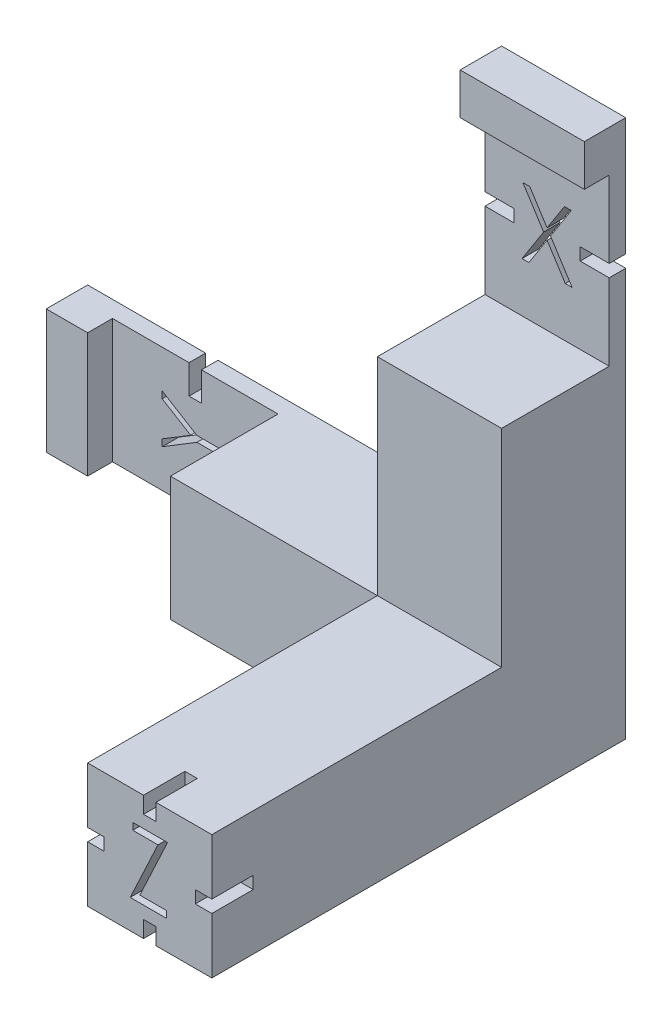
from build123d import *

# Parameters (mm, degrees)
CROQUIS2_W                = 25
CROQUIS2_H                = 15
SALIENTE_EXTRUIR1_DEPTH   = 15
CROQUIS2_W_2              = 15
CROQUIS2_H_2              = 25
SALIENTE_EXTRUIR1_2_DEPTH = 15
CROQUIS2_3_W              = 15
CROQUIS2_3_H              = 15
SALIENTE_EXTRUIR2_DEPTH   = 50
CROQUIS3_W                = 15
CROQUIS3_H                = 20
CROQUIS3_W_2              = 20
CROQUIS3_H_2              = 15
SALIENTE_EXTRUIR3_DEPTH   = 2
CROQUIS3_3_W              = 15
CROQUIS3_3_H              = 5
CROQUIS3_3_W_2            = 5
CROQUIS3_3_H_2            = 15
SALIENTE_EXTRUIR4_DEPTH   = 5
CROQUIS4_W                = 3.5
CROQUIS4_H                = 1.5
CROQUIS4_W_2              = 1.5
CROQUIS4_H_2              = 3.5
CORTAR_EXTRUIR1_DEPTH     = 15
CROQUIS5_W                = 1.5
CROQUIS5_H                = 2
CROQUIS5_W_2              = 2
CROQUIS5_H_2              = 1.5
CORTAR_EXTRUIR2_DEPTH     = 5


with BuildPart() as part:
    # Croquis2 → Saliente-Extruir1 (new body)
    with BuildSketch(Plane.XY):
        with Locations((-27.5, 7.5)):
            Rectangle(CROQUIS2_W, CROQUIS2_H)
    extrude(amount=SALIENTE_EXTRUIR1_DEPTH)



with BuildPart() as body_2:
    # Croquis2 → Saliente-Extruir1 2 (new body)
    with BuildSketch(Plane.XY):
        with Locations((-7.5, 27.5)):
            Rectangle(CROQUIS2_W_2, CROQUIS2_H_2)
    extrude(amount=SALIENTE_EXTRUIR1_2_DEPTH)


with BuildPart() as part_1:
    add(part.part)

    add(body_2.part)  # Saliente-Extruir2 merges body 2
    # Croquis2_3 → Saliente-Extruir2 (add)
    with BuildSketch(Plane.XY):
        with Locations((-7.5, 7.5)):
            Rectangle(CROQUIS2_3_W, CROQUIS2_3_H)
    extrude(amount=SALIENTE_EXTRUIR2_DEPTH)

    # Croquis3 → Saliente-Extruir3 (add)
    with BuildSketch(Plane.XY):
        with Locations((-7.5, 50)):
            Rectangle(CROQUIS3_W, CROQUIS3_H)
        with Locations((-50, 7.5)):
            Rectangle(CROQUIS3_W_2, CROQUIS3_H_2)
    extrude(amount=SALIENTE_EXTRUIR3_DEPTH)

    # Croquis3_3 → Saliente-Extruir4 (add)
    with BuildSketch(Plane.XY):
        with Locations((-7.5, 62.5)):
            Rectangle(CROQUIS3_3_W, CROQUIS3_3_H)
        with Locations((-62.5, 7.5)):
            Rectangle(CROQUIS3_3_W_2, CROQUIS3_3_H_2)
    extrude(amount=SALIENTE_EXTRUIR4_DEPTH)

    # Croquis4 → Cortar-Extruir1 (cut)
    with BuildSketch(Plane.XY.offset(2)):
        with Locations((-13.25, 50)):
            Rectangle(CROQUIS4_W, CROQUIS4_H)
        with Locations((-1.75, 50)):
            Rectangle(CROQUIS4_W, CROQUIS4_H)
        with Locations((-50, 13.25)):
            Rectangle(CROQUIS4_W_2, CROQUIS4_H_2)
        with Locations((-50, 1.75)):
            Rectangle(CROQUIS4_W_2, CROQUIS4_H_2)
        Polygon((-10.423076923, 54), (-9.594551282, 54), (-7.5, 50.727564103), (-5.405448718, 54), (-4.576923077, 54), (-7.084935897, 50.080128205), (-4.474358974, 46), (-5.302884615, 46), (-7.5, 49.432692308), (-9.697115385, 46), (-10.525641026, 46), (-7.913461538, 50.080128205), align=None)
        Polygon((-54, 10.423076923), (-54, 9.600961538), (-50.5625, 7.498397436), (-54, 5.399038462), (-54, 4.576923077), (-49.802884615, 7.141025641), (-46, 7.141025641), (-46, 7.858974359), (-49.802884615, 7.858974359), align=None)
    extrude(amount=-CORTAR_EXTRUIR1_DEPTH, mode=Mode.SUBTRACT)

    # Croquis5 → Cortar-Extruir2 (cut)
    with BuildSketch(Plane.XY.offset(50)):
        with Locations((-7.5, 14)):
            Rectangle(CROQUIS5_W, CROQUIS5_H)
        with Locations((-7.5, 1)):
            Rectangle(CROQUIS5_W, CROQUIS5_H)
        with Locations((-1, 7.5)):
            Rectangle(CROQUIS5_W_2, CROQUIS5_H_2)
        with Locations((-14, 7.5)):
            Rectangle(CROQUIS5_W_2, CROQUIS5_H_2)
        Polygon((-9.551282051, 10.679487179), (-9.551282051, 11.5), (-5.346153846, 11.5), (-8.701923077, 4.320512821), (-5.448717949, 4.320512821), (-5.448717949, 3.5), (-9.858974359, 3.5), (-6.503205128, 10.679487179), align=None)
    extrude(amount=-CORTAR_EXTRUIR2_DEPTH, mode=Mode.SUBTRACT)


solid = part_1.part
